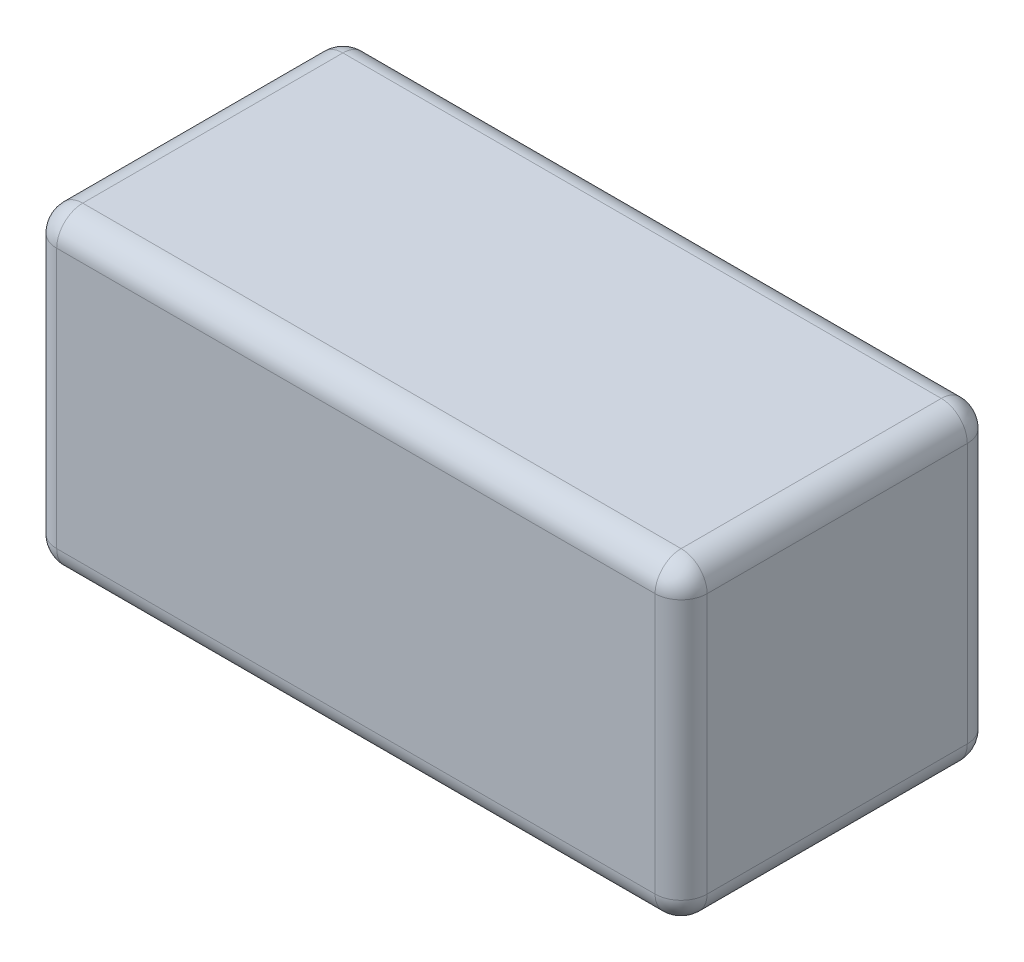
from build123d import *

# Parameters (mm, degrees)
SKETCH_1_W      = 50
SKETCH_1_H      = 24
EXTRUDE_1_DEPTH = 24
FILLET_1_R      = 2


with BuildPart() as part:
    # 草图1 → 凸台-拉伸1 (new body)
    with BuildSketch(Plane(origin=(0, 0, 0), x_dir=(1, 0, 0), z_dir=(0, 1, 0))):
        Rectangle(SKETCH_1_W, SKETCH_1_H)
    extrude(amount=EXTRUDE_1_DEPTH)

    # 圆角1
    fillet_1_edges = [part.edges().sort_by_distance(p)[0] for p in [
        (-25, 24, 0),
        (0, 24, 12),
        (25, 24, 0),
        (0, 0, 12),
        (-25, 0, 0),
        (0, 0, -12),
        (25, 0, 0),
        (0, 24, -12),
        (25, 12, 12),
        (-25, 12, 12),
        (-25, 12, -12),
        (25, 12, -12),
    ]]
    fillet(fillet_1_edges, radius=FILLET_1_R)


solid = part.part
